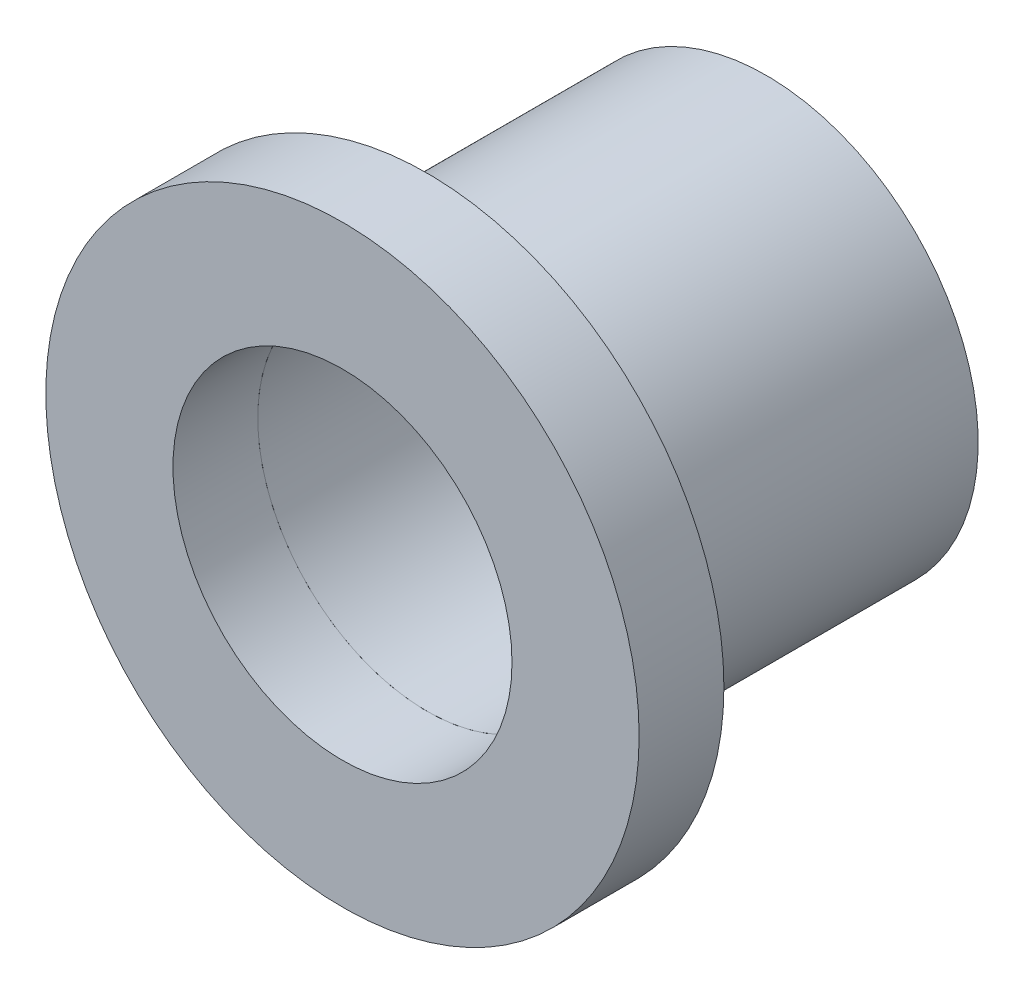
from build123d import *

# Parameters (mm, degrees)
SKETCH1_R           = 11.1125
SKETCH1_R_2         = 6.35
BOSS_EXTRUDE1_DEPTH = 3.175
SKETCH2_R           = 7.9375
SKETCH2_R_2         = 6.35
BOSS_EXTRUDE2_DEPTH = 12.7


with BuildPart() as part:
    # Sketch1 → Boss-Extrude1 (new body)
    with BuildSketch(Plane.XY):
        Circle(SKETCH1_R)
        Circle(SKETCH1_R_2, mode=Mode.SUBTRACT)
    extrude(amount=BOSS_EXTRUDE1_DEPTH)


with BuildPart() as body_2:
    # Sketch2 → Boss-Extrude2 (new body)
    with BuildSketch(Plane(origin=(0, 0, 0), x_dir=(-1, 0, 0), z_dir=(0, 0, -1))):
        Circle(SKETCH2_R)
        Circle(SKETCH2_R_2, mode=Mode.SUBTRACT)
    extrude(amount=BOSS_EXTRUDE2_DEPTH)


solid = Compound([part.part, body_2.part])
